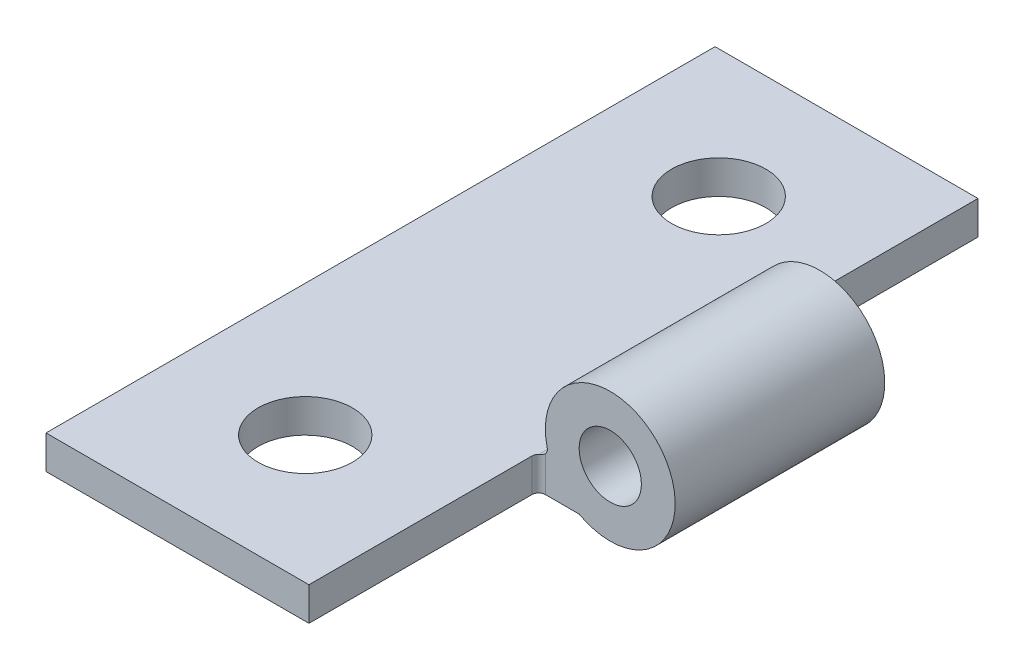
from build123d import *

# Parameters (mm, degrees)
SKETCH1_R           = 1.1811
BOSS_EXTRUDE1_DEPTH = 25.4
FILLET2_R           = 0.254
SKETCH2_R           = 2.4638
CUT_EXTRUDE1_DEPTH  = 8.72109
SKETCH3_R           = 2.4638
CUT_EXTRUDE2_DEPTH  = 8.72109
SKETCH5_W           = 1.7273194
SKETCH5_H           = 1.763863254
CUT_EXTRUDE3_DEPTH  = 8.72109
SKETCH6_W           = 1.964621561
SKETCH6_H           = 1.893145227
CUT_EXTRUDE4_DEPTH  = 8.72109
FILLET3_R           = 0.254
FILLET4_R           = 0.254
SKETCH7_R           = 1.7907
CUT_EXTRUDE5_DEPTH  = 2.54


with BuildPart() as part:
    # Sketch1 → Boss-Extrude1 (new body)
    with BuildSketch(Plane.XY):
        with BuildLine():
            Line((-17.6276, 2.614576368), (-17.6276, 3.884576368))
            Line((-17.6276, 3.884576368), (-7.224163794, 3.884576368))
            ThreePointArc((-7.224163794, 3.884576368), (-3.076448638, 6.402723098), (-6.1087, 2.614576368))
            Line((-6.1087, 2.614576368), (-17.6276, 2.614576368))
        make_face()
        with Locations((-4.9276, 4.776823632)):
            Circle(SKETCH1_R, mode=Mode.SUBTRACT)
    extrude(amount=BOSS_EXTRUDE1_DEPTH)

    # Fillet2
    fillet2_edges = [part.edges().sort_by_distance(p)[0] for p in [
        (-7.224163794, 3.884576368, 12.7),
    ]]
    fillet(fillet2_edges, radius=FILLET2_R)

    # Sketch2 → Cut-Extrude1 (cut)
    with BuildSketch(Plane(origin=(0, 0, 0), x_dir=(-1, 0, 0), z_dir=(0, 0, -1))):
        with Locations((4.9276, 4.776823632)):
            Circle(SKETCH2_R)
    extrude(amount=-CUT_EXTRUDE1_DEPTH, mode=Mode.SUBTRACT)

    # Sketch3 → Cut-Extrude2 (cut)
    with BuildSketch(Plane.XY.offset(25.4)):
        with Locations((-4.9276, 4.776823632)):
            Circle(SKETCH3_R)
    extrude(amount=-CUT_EXTRUDE2_DEPTH, mode=Mode.SUBTRACT)

    # Sketch5 → Cut-Extrude3 (cut)
    with BuildSketch(Plane(origin=(0, 0, 0), x_dir=(-1, 0, 0), z_dir=(0, 0, -1))):
        with Locations((6.7817403, 3.496507995)):
            Rectangle(SKETCH5_W, SKETCH5_H)
    extrude(amount=-CUT_EXTRUDE3_DEPTH, mode=Mode.SUBTRACT)

    # Sketch6 → Cut-Extrude4 (cut)
    with BuildSketch(Plane.XY.offset(25.4)):
        with Locations((-6.663089219, 3.561148982)):
            Rectangle(SKETCH6_W, SKETCH6_H)
    extrude(amount=-CUT_EXTRUDE4_DEPTH, mode=Mode.SUBTRACT)

    # Fillet3
    fillet3_edges = [part.edges().sort_by_distance(p)[0] for p in [
        (-7.6454, 3.249576368, 16.67891),
    ]]
    fillet(fillet3_edges, radius=FILLET3_R)

    # Fillet4
    fillet4_edges = [part.edges().sort_by_distance(p)[0] for p in [
        (-7.6454, 3.249576368, 8.72109),
    ]]
    fillet(fillet4_edges, radius=FILLET4_R)

    # Sketch7 → Cut-Extrude5 (cut)
    with BuildSketch(Plane(origin=(0, 3.884576368, 0), x_dir=(1, 0, 0), z_dir=(0, 1, 0))):
        with Locations((-12.6365, -4.8514)):
            Circle(SKETCH7_R)
        with Locations((-12.6365, -20.5486)):
            Circle(SKETCH7_R)
    extrude(amount=-CUT_EXTRUDE5_DEPTH, mode=Mode.SUBTRACT)


solid = part.part
